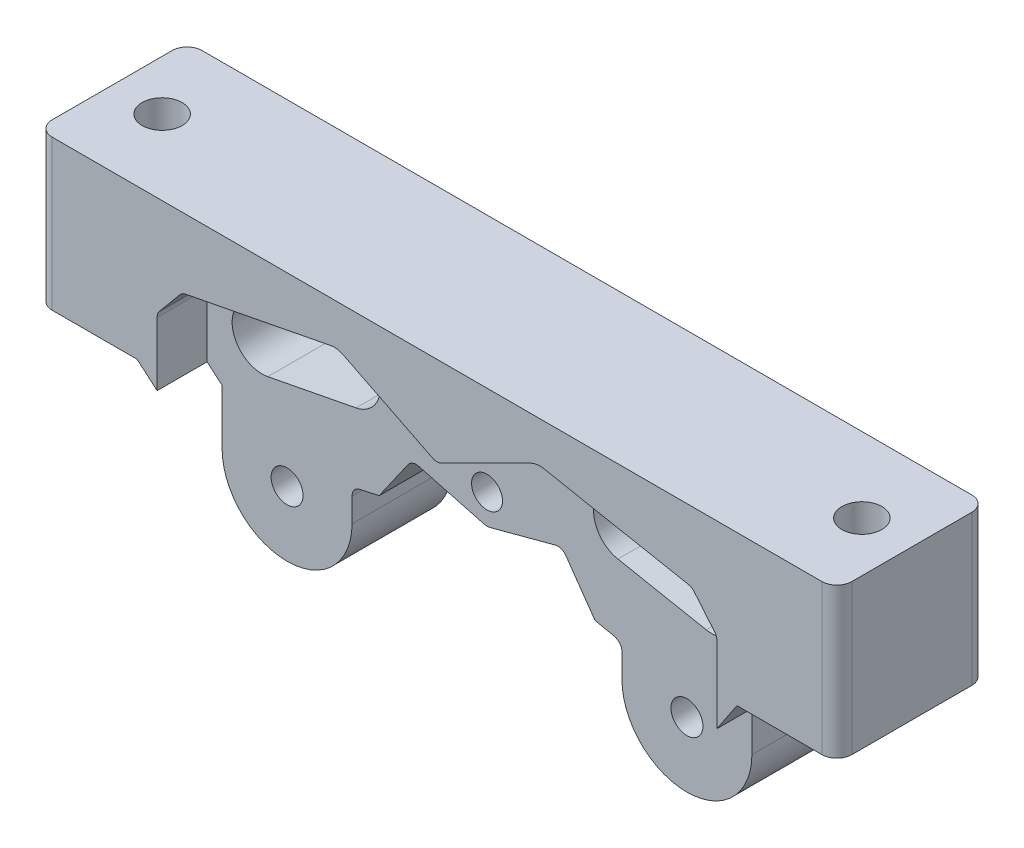
from build123d import *

# Parameters (mm, degrees)
BOSS_EXTRUDE1_DEPTH = 15
CUT_EXTRUDE7_DEPTH  = 5
CUT_EXTRUDE8_DEPTH  = 35
SKETCH3_R           = 1.55
CUT_EXTRUDE10_DEPTH = 32
SKETCH10_R          = 1.6
CUT_EXTRUDE11_DEPTH = 32
SKETCH11_R          = 4.1
CUT_EXTRUDE12_DEPTH = 0.4
CUT_EXTRUDE13_DEPTH = 32
SKETCH14_R          = 2
CUT_EXTRUDE14_DEPTH = 22
CUT_EXTRUDE15_DEPTH = 3
SKETCH16_W          = 38
SKETCH16_H          = 15
CUT_EXTRUDE16_DEPTH = 20
CUT_EXTRUDE17_DEPTH = 20


with BuildPart() as part:
    # Sketch1 → Boss-Extrude1 (new body)
    with BuildSketch(Plane.XY):
        Polygon((0, 0), (48, 0), (48, -15), (108, -15), (108, 0), (156, 0), (156, 15), (0, 15), align=None)
    extrude(amount=BOSS_EXTRUDE1_DEPTH)

    # Sketch2 → Cut-Extrude7 (cut)
    with BuildSketch(Plane.XY.offset(15)):
        with BuildLine():
            Line((77.552786405, 6.223606798), (68.60756702, 10.69621649))
            ThreePointArc((68.60756702, 10.69621649), (67.984760984, 10.888831752), (67.333096015, 10.870921809))
            Line((67.333096015, 10.870921809), (52.849985824, 8.067739192))
            ThreePointArc((52.849985824, 8.067739192), (52.531353266, 7.946930093), (52.271786451, 7.726143741))
            Line((52.271786451, 7.726143741), (50.23177872, 5.278134464))
            ThreePointArc((50.23177872, 5.278134464), (50.059728422, 4.978375329), (50, 4.637950065))
            Line((50, 4.637950065), (50, -15))
            Line((50, -15), (106, -15))
            Line((106, -15), (106, 4.637950065))
            ThreePointArc((106, 4.637950065), (105.940271578, 4.978375329), (105.76822128, 5.278134464))
            Line((105.76822128, 5.278134464), (103.728213549, 7.726143741))
            ThreePointArc((103.728213549, 7.726143741), (103.468646734, 7.946930093), (103.150014176, 8.067739192))
            Line((103.150014176, 8.067739192), (88.666903985, 10.870921809))
            ThreePointArc((88.666903985, 10.870921809), (88.015239016, 10.888831752), (87.39243298, 10.69621649))
            Line((87.39243298, 10.69621649), (78.447213595, 6.223606798))
            ThreePointArc((78.447213595, 6.223606798), (78, 6.118033989), (77.552786405, 6.223606798))
        make_face()
    extrude(amount=-CUT_EXTRUDE7_DEPTH, mode=Mode.SUBTRACT)

    # Sketch4 → Cut-Extrude8 (cut)
    with BuildSketch(Plane.XY.offset(15)):
        with BuildLine():
            Line((78.257662651, -1.93128996), (78, -1.960923359))
            Line((78, -1.960923359), (77.742337349, -1.93128996))
            Line((77.742337349, -1.93128996), (71.175803726, -0.180214327))
            ThreePointArc((71.175803726, -0.180214327), (70.575493167, -0.206985371), (70.098909155, -0.572986922))
            Line((70.098909155, -0.572986922), (67.200935386, -4.712949448))
            ThreePointArc((67.200935386, -4.712949448), (67.05739096, -5.016112502), (67.022171235, -5.349687697))
            Line((67.022171235, -5.349687697), (67.574638514, -14.063275904))
            ThreePointArc((67.574638514, -14.063275904), (67.888264768, -14.729135071), (68.572634586, -15))
            Line((68.572634586, -15), (87.427365414, -15))
            ThreePointArc((87.427365414, -15), (88.111735232, -14.729135071), (88.425361486, -14.063275904))
            Line((88.425361486, -14.063275904), (88.977828765, -5.349687697))
            ThreePointArc((88.977828765, -5.349687697), (88.94260904, -5.016112502), (88.799064614, -4.712949448))
            Line((88.799064614, -4.712949448), (85.901090845, -0.572986922))
            ThreePointArc((85.901090845, -0.572986922), (85.424506833, -0.206985371), (84.824196274, -0.180214327))
            Line((84.824196274, -0.180214327), (78.257662651, -1.93128996))
        make_face()
    extrude(amount=-CUT_EXTRUDE8_DEPTH, mode=Mode.SUBTRACT)

    # Sketch3 → Cut-Extrude10 (cut)
    with BuildSketch(Plane.XY.offset(15)):
        with Locations((78, 1)):
            Circle(SKETCH3_R)
    extrude(amount=-CUT_EXTRUDE10_DEPTH, mode=Mode.SUBTRACT)

    # Sketch10 → Cut-Extrude11 (cut)
    with BuildSketch(Plane.XY.offset(10)):
        with Locations((98, -8.5)):
            Circle(SKETCH10_R)
        with Locations((58, -8.5)):
            Circle(SKETCH10_R)
        with BuildLine():
            Line((54.92993428, 5.92391415), (63.765952936, 7.634111309))
            ThreePointArc((63.765952936, 7.634111309), (67.281358207, 5.258837477), (64.906084375, 1.743432206))
            Line((64.906084375, 1.743432206), (56.07006572, 0.033235047))
            ThreePointArc((56.07006572, 0.033235047), (52.554660448, 2.408508879), (54.92993428, 5.92391415))
        make_face()
        with BuildLine():
            Line((101.07006572, 5.92391415), (92.234047064, 7.634111309))
            ThreePointArc((92.234047064, 7.634111309), (88.718641793, 5.258837477), (91.093915625, 1.743432206))
            Line((91.093915625, 1.743432206), (99.92993428, 0.033235047))
            ThreePointArc((99.92993428, 0.033235047), (103.445339552, 2.408508879), (101.07006572, 5.92391415))
        make_face()
    extrude(amount=-CUT_EXTRUDE11_DEPTH, mode=Mode.SUBTRACT)

    # Sketch11 → Cut-Extrude12 (cut)
    with BuildSketch(Plane(origin=(0, 0, 0), x_dir=(-1, 0, 0), z_dir=(0, 0, -1))):
        with Locations((-58, -8.5)):
            Circle(SKETCH11_R)
        with Locations((-98, -8.5)):
            Circle(SKETCH11_R)
    extrude(amount=-CUT_EXTRUDE12_DEPTH, mode=Mode.SUBTRACT)

    # Sketch13 → Cut-Extrude13 (cut)
    with BuildSketch(Plane(origin=(0, 0, 0), x_dir=(-1, 0, 0), z_dir=(0, 0, -1))):
        with BuildLine():
            Line((-108, -15), (-98, -15))
            ThreePointArc((-98, -15), (-102.596194078, -13.096194078), (-104.5, -8.5))
            Line((-104.5, -8.5), (-104.5, -4))
            ThreePointArc((-104.5, -4), (-104.792893219, -3.292893219), (-105.5, -3))
            Line((-105.5, -3), (-106, -3))
            Line((-106, -3), (-108, 0))
            Line((-108, 0), (-108, -15))
        make_face()
        with BuildLine():
            Line((-91.5, -6.096383305), (-91.5, -8.5))
            ThreePointArc((-91.5, -8.5), (-93.403805922, -13.096194078), (-98, -15))
            Line((-98, -15), (-87.427365414, -15))
            Line((-87.427365414, -15), (-88.799064614, -4.712949448))
            Line((-88.799064614, -4.712949448), (-90.707690196, -5.11818865))
            ThreePointArc((-90.707690196, -5.11818865), (-91.277074706, -5.46697493), (-91.5, -6.096383305))
        make_face()
        with BuildLine():
            ThreePointArc((-51.5, -8.5), (-53.403805922, -13.096194078), (-58, -15))
            Line((-58, -15), (-48, -15))
            Line((-48, -15), (-48, 0))
            Line((-48, 0), (-51.5, -3))
            Line((-51.5, -3), (-51.5, -8.5))
        make_face()
        with BuildLine():
            Line((-67.200935386, -4.712949448), (-68.572634586, -15))
            Line((-68.572634586, -15), (-58, -15))
            ThreePointArc((-58, -15), (-62.596194078, -13.096194078), (-64.5, -8.5))
            Line((-64.5, -8.5), (-64.5, -6.096383305))
            ThreePointArc((-64.5, -6.096383305), (-64.722925294, -5.46697493), (-65.292309804, -5.11818865))
            Line((-65.292309804, -5.11818865), (-67.200935386, -4.712949448))
        make_face()
    extrude(amount=-CUT_EXTRUDE13_DEPTH, mode=Mode.SUBTRACT)

    # Sketch14 → Cut-Extrude14 (cut)
    with BuildSketch(Plane(origin=(0, 15, 0), x_dir=(1, 0, 0), z_dir=(0, 1, 0))):
        with Locations((113, -7.5)):
            Circle(SKETCH14_R)
        with Locations((43, -7.5)):
            Circle(SKETCH14_R)
    extrude(amount=-CUT_EXTRUDE14_DEPTH, mode=Mode.SUBTRACT)

    # Sketch15 → Cut-Extrude15 (cut)
    with BuildSketch(Plane.XZ):
        Polygon((117.041451884, 7.5), (115.020725942, 11), (110.979274058, 11), (108.958548116, 7.5), (110.979274058, 4), (115.020725942, 4), align=None)
        Polygon((38.958548116, 7.5), (40.979274058, 4), (45.020725942, 4), (47.041451884, 7.5), (45.020725942, 11), (40.979274058, 11), align=None)
    extrude(amount=-CUT_EXTRUDE15_DEPTH, mode=Mode.SUBTRACT)

    # Sketch16 → Cut-Extrude16 (cut)
    with BuildSketch(Plane(origin=(0, 15, 0), x_dir=(1, 0, 0), z_dir=(0, 1, 0))):
        with Locations((137, -7.5)):
            Rectangle(SKETCH16_W, SKETCH16_H)
        with Locations((19, -7.5)):
            Rectangle(SKETCH16_W, SKETCH16_H)
    extrude(amount=-CUT_EXTRUDE16_DEPTH, mode=Mode.SUBTRACT)

    # Sketch17 → Cut-Extrude17 (cut)
    with BuildSketch(Plane(origin=(0, 15, 0), x_dir=(1, 0, 0), z_dir=(0, 1, 0))):
        with BuildLine():
            Line((118, -13.5), (118, -15))
            Line((118, -15), (116.5, -15))
            ThreePointArc((116.5, -15), (117.560660172, -14.560660172), (118, -13.5))
        make_face()
        with BuildLine():
            Line((116.5, 0), (118, 0))
            Line((118, 0), (118, -1.5))
            ThreePointArc((118, -1.5), (117.560660172, -0.439339828), (116.5, 0))
        make_face()
        with BuildLine():
            Line((39.5, 0), (38, 0))
            Line((38, 0), (38, -1.5))
            ThreePointArc((38, -1.5), (38.439339828, -0.439339828), (39.5, 0))
        make_face()
        with BuildLine():
            Line((39.5, -15), (38, -15))
            Line((38, -15), (38, -13.5))
            ThreePointArc((38, -13.5), (38.439339828, -14.560660172), (39.5, -15))
        make_face()
    extrude(amount=-CUT_EXTRUDE17_DEPTH, mode=Mode.SUBTRACT)


solid = part.part
